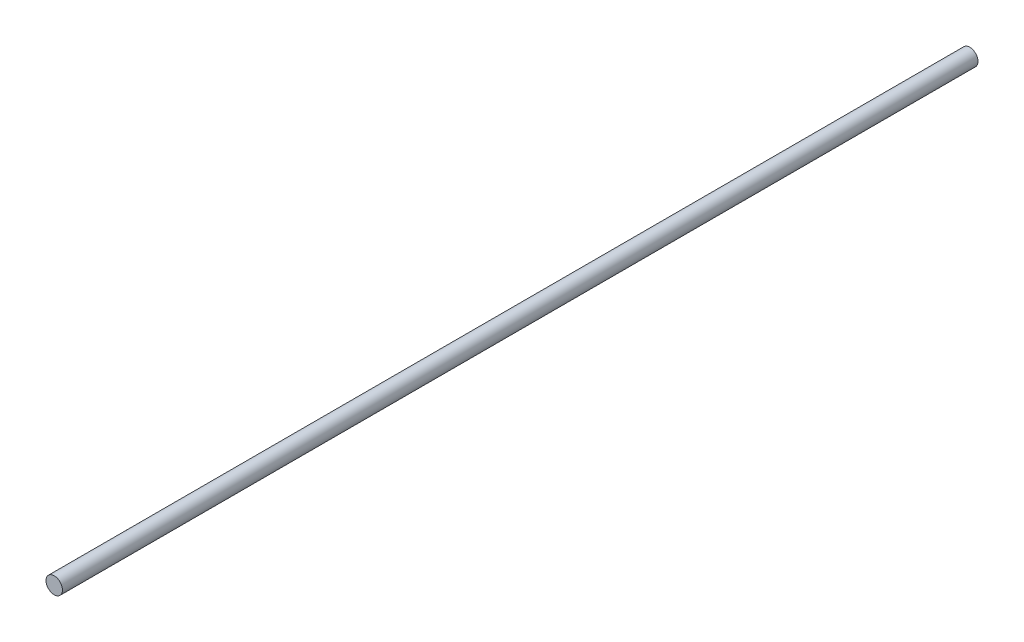
from build123d import *

# Parameters (mm, degrees)
SKETCH2_R           = 22.5
BOSS_EXTRUDE1_DEPTH = 2500


with BuildPart() as part:
    # Sketch2 → Boss-Extrude1 (new body)
    with BuildSketch(Plane.XY):
        Circle(SKETCH2_R)
    extrude(amount=BOSS_EXTRUDE1_DEPTH)


solid = part.part
